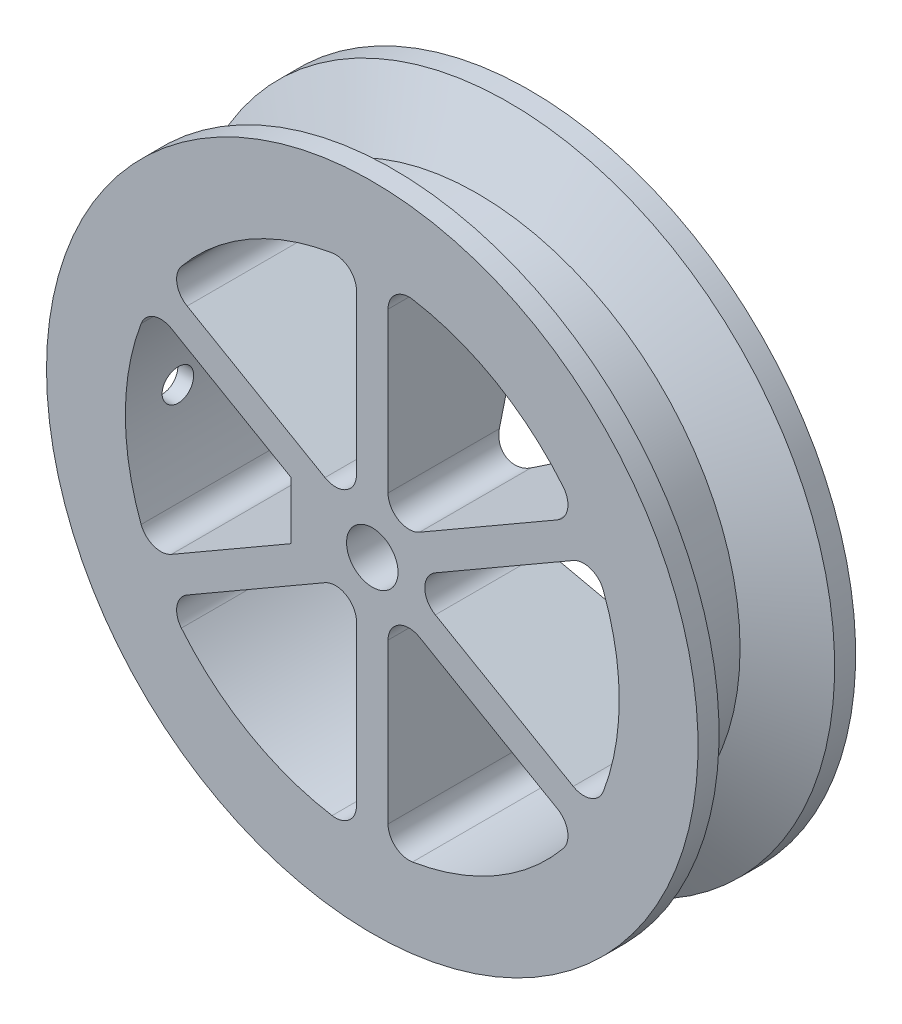
from build123d import *

# Parameters (mm, degrees)
SKETCH4_R                 = 3.1115
CUT_EXTRUDE1_DEPTH        = 20.05
CUT_EXTRUDE2_DEPTH        = 20.05
CIRPATTERN1_COUNT         = 6
SKETCH6_W                 = 5.08
SKETCH6_H                 = 6.929069256
BOSS_EXTRUDE2_DEPTH       = 19.05
F_4_CLEARANCE_HOLE1_D     = 3.4544
F_4_CLEARANCE_HOLE1_DEPTH = 12.7
F_4_CLEARANCE_HOLE1_TIP   = 1.037806461
SKETCH10_R                = 1.905
CUT_EXTRUDE3_DEPTH        = 30.55925
CUT_EXTRUDE7_START        = -1.778
CUT_EXTRUDE7_DEPTH        = 2.413


with BuildPart() as part:
    # Sketch2 → Revolve1 (revolve)
    with BuildSketch(Plane(origin=(0, 0, 0), x_dir=(1, 0, 0), z_dir=(0, 1, 0))):
        Polygon((0, 9.525), (39.37, 9.525), (39.37, 6.985), (31.75, 3.175), (31.75, -6.985), (39.37, -6.985), (39.37, -9.525), (0, -9.525), align=None)
    revolve(axis=Axis((0, 0, -9.525), (0, 0, 1)))

    # Sketch4 → Cut-Extrude1 (cut, through all)
    with BuildSketch(Plane.XY.offset(9.525)):
        Circle(SKETCH4_R)
    extrude(amount=-CUT_EXTRUDE1_DEPTH, mode=Mode.SUBTRACT)

    # Sketch5 → Cut-Extrude2 (cut, through all)
    with BuildSketch(Plane.XY.offset(9.525)):
        with BuildLine():
            Line((5.715, 5.499261314), (22.3788898, 15.120162576))
            ThreePointArc((22.3788898, 15.120162576), (23.607834508, 16.865031588), (23.072507456, 18.931017529))
            ThreePointArc((23.072507456, 18.931017529), (14.9225, 25.846528176), (4.858488372, 29.44688635))
            ThreePointArc((4.858488372, 29.44688635), (2.801628536, 28.877500206), (1.905, 26.940768363))
            Line((1.905, 26.940768363), (1.905, 7.69896584))
            ThreePointArc((1.905, 7.69896584), (3.175, 5.499261314), (5.715, 5.499261314))
        make_face()
    cut_extrude2 = extrude(amount=-CUT_EXTRUDE2_DEPTH, mode=Mode.SUBTRACT)

    # CirPattern1: Cut-Extrude2 ×6 about axis
    cirpattern1_axis = Axis((0, 0, 0), (0, 0, 1))
    for i in range(1, CIRPATTERN1_COUNT):
        add(cut_extrude2.rotate(cirpattern1_axis, i * 360 / CIRPATTERN1_COUNT), mode=Mode.SUBTRACT)

    # Sketch6 → Boss-Extrude2 (add, through all)
    with BuildSketch(Plane.XY.offset(9.525)):
        with Locations((-7.27075, 0)):
            Rectangle(SKETCH6_W, SKETCH6_H)
    extrude(amount=-BOSS_EXTRUDE2_DEPTH)

    # 4 Clearance Hole1
    with Locations(Plane.ZY.offset(9.81075)):
        with Locations((3.175, 0)):
            Hole(F_4_CLEARANCE_HOLE1_D / 2, depth=F_4_CLEARANCE_HOLE1_DEPTH)
            with Locations((0, 0, -(F_4_CLEARANCE_HOLE1_DEPTH + F_4_CLEARANCE_HOLE1_TIP / 2))):  # 118° drill point
                Cone(0, F_4_CLEARANCE_HOLE1_D / 2, F_4_CLEARANCE_HOLE1_TIP, mode=Mode.SUBTRACT)

    # Sketch10 → Cut-Extrude3 (cut, through all)
    with BuildSketch(Plane.ZY.offset(9.81075)):
        with Locations((3.175, 0)):
            Circle(SKETCH10_R)
    extrude(amount=CUT_EXTRUDE3_DEPTH, mode=Mode.SUBTRACT)

    # Sketch15 → Cut-Extrude7 (cut)
    with BuildSketch(Plane.ZY.offset(9.81075).offset(CUT_EXTRUDE7_START)):
        Polygon((-9.525, -3.429), (5.154734073, -3.429), (7.134468146, 0), (5.154734073, 3.429), (-9.525, 3.429), align=None)
    extrude(amount=-CUT_EXTRUDE7_DEPTH, mode=Mode.SUBTRACT)

    # Sketch16 → Cut-Revolve1 (revolve, cut)
    with BuildSketch(Plane(origin=(0, 0, 0), x_dir=(1, 0, 0), z_dir=(0, 1, 0))):
        Polygon((0, 1.905), (29.845, 9.525), (0, 9.525), align=None)
    revolve(axis=Axis((0, 0, 9.525), (0, 0, -1)), mode=Mode.SUBTRACT)


solid = part.part
